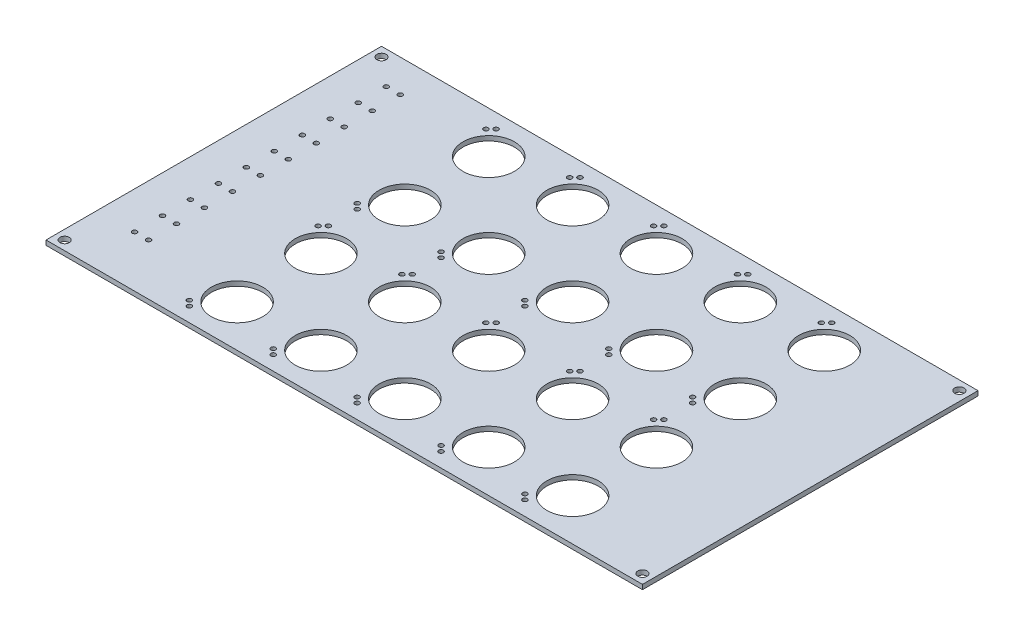
from build123d import *

# Parameters (mm, degrees)
SKETCH1_W           = 812.8
SKETCH1_H           = 457.2
BOSS_EXTRUDE1_DEPTH = 6.35
SKETCH3_R           = 35
SKETCH3_R_2         = 3.175
SKETCH3_R_3         = 6.35
CUT_EXTRUDE1_DEPTH  = 6.35


with BuildPart() as part:
    # Sketch1 → Boss-Extrude1 (new body)
    with BuildSketch(Plane(origin=(0, 0, 0), x_dir=(1, 0, 0), z_dir=(0, 1, 0))):
        with Locations((-36.138533541, -41.56723869)):
            Rectangle(SKETCH1_W, SKETCH1_H)
    extrude(amount=BOSS_EXTRUDE1_DEPTH)

    # Sketch3 → Cut-Extrude1 (cut)
    with BuildSketch(Plane(origin=(0, 6.35, 0), x_dir=(1, 0, 0), z_dir=(0, 1, 0))):
        with Locations((-239.338533541, 129.88276131)):
            Circle(SKETCH3_R)
        with Locations((-125.038533541, 129.88276131)):
            Circle(SKETCH3_R)
        with Locations((-10.738533541, 129.88276131)):
            Circle(SKETCH3_R)
        with Locations((103.561466459, 129.88276131)):
            Circle(SKETCH3_R)
        with Locations((217.861466459, 129.88276131)):
            Circle(SKETCH3_R)
        with Locations((-125.038533541, 15.58276131)):
            Circle(SKETCH3_R)
        with Locations((-10.738533541, 15.58276131)):
            Circle(SKETCH3_R)
        with Locations((103.561466459, 15.58276131)):
            Circle(SKETCH3_R)
        with Locations((217.861466459, 15.58276131)):
            Circle(SKETCH3_R)
        with Locations((-239.338533541, 15.58276131)):
            Circle(SKETCH3_R)
        with Locations((-391.738533541, 142.58276131)):
            Circle(SKETCH3_R_2)
        with Locations((-372.688533541, 142.58276131)):
            Circle(SKETCH3_R_2)
        with Locations((-372.688533541, 104.48276131)):
            Circle(SKETCH3_R_2)
        with Locations((-372.688533541, 66.38276131)):
            Circle(SKETCH3_R_2)
        with Locations((-372.688533541, 28.28276131)):
            Circle(SKETCH3_R_2)
        with Locations((-372.688533541, -9.81723869)):
            Circle(SKETCH3_R_2)
        with Locations((-372.688533541, -47.91723869)):
            Circle(SKETCH3_R_2)
        with Locations((-372.688533541, -86.01723869)):
            Circle(SKETCH3_R_2)
        with Locations((-372.688533541, -124.11723869)):
            Circle(SKETCH3_R_2)
        with Locations((-372.688533541, -162.21723869)):
            Circle(SKETCH3_R_2)
        with Locations((-372.688533541, -200.31723869)):
            Circle(SKETCH3_R_2)
        with Locations((-391.738533541, 104.48276131)):
            Circle(SKETCH3_R_2)
        with Locations((-391.738533541, 66.38276131)):
            Circle(SKETCH3_R_2)
        with Locations((-391.738533541, 28.28276131)):
            Circle(SKETCH3_R_2)
        with Locations((-391.738533541, -9.81723869)):
            Circle(SKETCH3_R_2)
        with Locations((-391.738533541, -47.91723869)):
            Circle(SKETCH3_R_2)
        with Locations((-391.738533541, -86.01723869)):
            Circle(SKETCH3_R_2)
        with Locations((-391.738533541, -124.11723869)):
            Circle(SKETCH3_R_2)
        with Locations((-391.738533541, -162.21723869)):
            Circle(SKETCH3_R_2)
        with Locations((-391.738533541, -200.31723869)):
            Circle(SKETCH3_R_2)
        with Locations((-429.838533541, 174.33276131)):
            Circle(SKETCH3_R_3)
        with Locations((-429.838533541, -257.46723869)):
            Circle(SKETCH3_R_3)
        with Locations((357.561466459, -257.46723869)):
            Circle(SKETCH3_R_3)
        with Locations((357.561466459, 174.33276131)):
            Circle(SKETCH3_R_3)
        with Locations((-266.770533541, 167.42276131)):
            Circle(SKETCH3_R_2)
        with Locations((-273.775133316, 160.418161536)):
            Circle(SKETCH3_R_2)
        with Locations((-152.470533541, 167.42276131)):
            Circle(SKETCH3_R_2)
        with Locations((-159.475133316, 160.418161536)):
            Circle(SKETCH3_R_2)
        with Locations((-38.170533541, 167.42276131)):
            Circle(SKETCH3_R_2)
        with Locations((-45.175133316, 160.418161536)):
            Circle(SKETCH3_R_2)
        with Locations((76.129466459, 167.42276131)):
            Circle(SKETCH3_R_2)
        with Locations((69.124866684, 160.418161536)):
            Circle(SKETCH3_R_2)
        with Locations((190.429466459, 167.42276131)):
            Circle(SKETCH3_R_2)
        with Locations((183.424866684, 160.418161536)):
            Circle(SKETCH3_R_2)
        with Locations((190.429466459, -21.95723869)):
            Circle(SKETCH3_R_2)
        with Locations((76.129466459, -21.95723869)):
            Circle(SKETCH3_R_2)
        with Locations((69.124866684, -14.952638915)):
            Circle(SKETCH3_R_2)
        with Locations((183.424866684, -14.952638915)):
            Circle(SKETCH3_R_2)
        with Locations((-38.170533541, -21.95723869)):
            Circle(SKETCH3_R_2)
        with Locations((-45.175133316, -14.952638915)):
            Circle(SKETCH3_R_2)
        with Locations((-152.470533541, -21.95723869)):
            Circle(SKETCH3_R_2)
        with Locations((-159.475133316, -14.952638915)):
            Circle(SKETCH3_R_2)
        with Locations((-266.770533541, -21.95723869)):
            Circle(SKETCH3_R_2)
        with Locations((-273.775133316, -14.952638915)):
            Circle(SKETCH3_R_2)
        with Locations((-273.775133316, -68.181838464)):
            Circle(SKETCH3_R_2)
        with Locations((-266.770533541, -61.17723869)):
            Circle(SKETCH3_R_2)
        with Locations((-159.475133316, -68.181838464)):
            Circle(SKETCH3_R_2)
        with Locations((-152.470533541, -61.17723869)):
            Circle(SKETCH3_R_2)
        with Locations((-45.175133316, -68.181838464)):
            Circle(SKETCH3_R_2)
        with Locations((-38.170533541, -61.17723869)):
            Circle(SKETCH3_R_2)
        with Locations((183.424866684, -68.181838464)):
            Circle(SKETCH3_R_2)
        with Locations((69.124866684, -68.181838464)):
            Circle(SKETCH3_R_2)
        with Locations((76.129466459, -61.17723869)):
            Circle(SKETCH3_R_2)
        with Locations((190.429466459, -61.17723869)):
            Circle(SKETCH3_R_2)
        with Locations((183.424866684, -243.552638915)):
            Circle(SKETCH3_R_2)
        with Locations((190.429466459, -250.55723869)):
            Circle(SKETCH3_R_2)
        with Locations((69.124866684, -243.552638915)):
            Circle(SKETCH3_R_2)
        with Locations((76.129466459, -250.55723869)):
            Circle(SKETCH3_R_2)
        with Locations((-45.175133316, -243.552638915)):
            Circle(SKETCH3_R_2)
        with Locations((-38.170533541, -250.55723869)):
            Circle(SKETCH3_R_2)
        with Locations((-159.475133316, -243.552638915)):
            Circle(SKETCH3_R_2)
        with Locations((-152.470533541, -250.55723869)):
            Circle(SKETCH3_R_2)
        with Locations((-273.775133316, -243.552638915)):
            Circle(SKETCH3_R_2)
        with Locations((-266.770533541, -250.55723869)):
            Circle(SKETCH3_R_2)
        with Locations((-239.338533541, -98.71723869)):
            Circle(SKETCH3_R)
        with Locations((217.861466459, -98.71723869)):
            Circle(SKETCH3_R)
        with Locations((103.561466459, -98.71723869)):
            Circle(SKETCH3_R)
        with Locations((-10.738533541, -98.71723869)):
            Circle(SKETCH3_R)
        with Locations((-125.038533541, -98.71723869)):
            Circle(SKETCH3_R)
        with Locations((217.861466459, -213.01723869)):
            Circle(SKETCH3_R)
        with Locations((103.561466459, -213.01723869)):
            Circle(SKETCH3_R)
        with Locations((-10.738533541, -213.01723869)):
            Circle(SKETCH3_R)
        with Locations((-125.038533541, -213.01723869)):
            Circle(SKETCH3_R)
        with Locations((-239.338533541, -213.01723869)):
            Circle(SKETCH3_R)
    extrude(amount=-CUT_EXTRUDE1_DEPTH, mode=Mode.SUBTRACT)


solid = part.part
